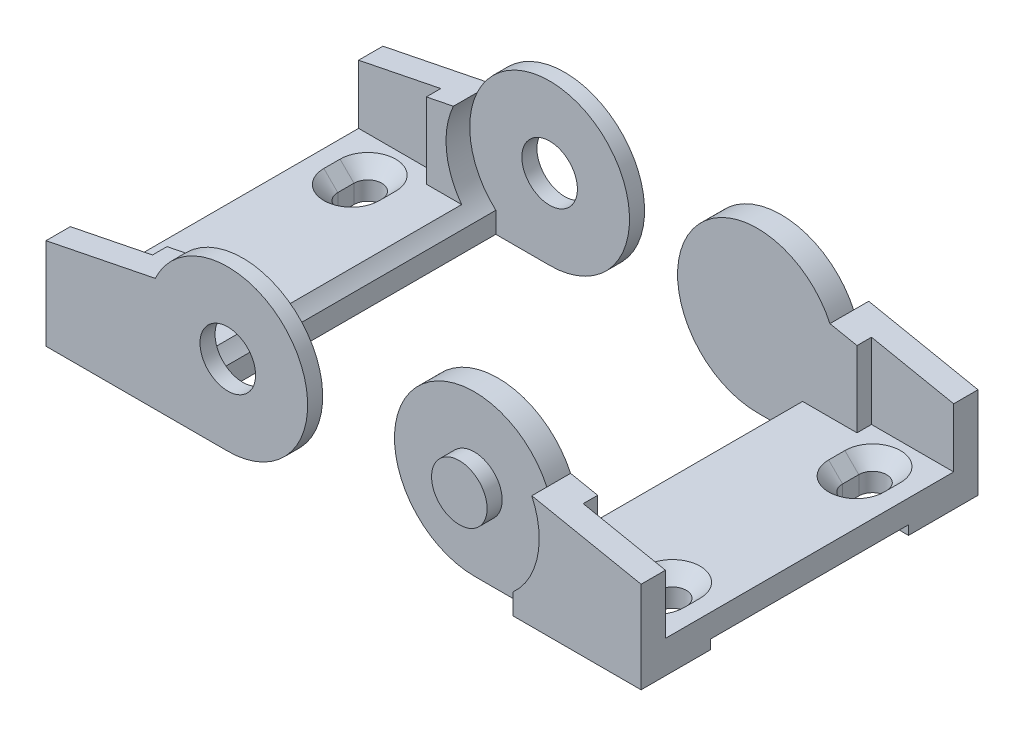
from build123d import *

# Parameters (mm, degrees)
EXTRUDE1_DEPTH          = 36.957
CUT_EXTRUDE1_DEPTH      = 31.623
CUT_EXTRUDE1_DEPTH_BACK = 31.623
CUT_EXTRUDE2_DEPTH      = 28.448
SKETCH5_R               = 6.096
CUT_EXTRUDE3_DEPTH      = 3.302
SKETCH6_W               = 6.096
SKETCH6_H               = 43.434
CUT_EXTRUDE4_DEPTH      = 2.032
CUT_EXTRUDE5_DEPTH      = 4.064
CUT_EXTRUDE6_DEPTH      = 3.048
CUT_EXTRUDE6_TAPER      = -45
EXTRUDE2_DEPTH          = 3.302
EXTRUDE3_DEPTH          = 3.302
CUT_EXTRUDE7_START      = -33.655
CUT_EXTRUDE7_DEPTH      = 67.31
SKETCH9_R               = 6.096
CUT_EXTRUDE8_DEPTH      = 74.914


with BuildPart() as part:
    # Sketch2 → Extrude1 (new body, symmetric)
    with BuildSketch(Plane.XY):
        with BuildLine():
            Line((0, -17.526), (39.878, -17.526))
            Line((39.878, -17.526), (39.878, 2.54))
            Line((39.878, 2.54), (15.902915456, 7.366))
            ThreePointArc((15.902915456, 7.366), (-14.769177228, 9.435681215), (0, -17.526))
        make_face()
    extrude(amount=EXTRUDE1_DEPTH, both=True)

    # Sketch3 → Cut-Extrude1 (cut, two sides)
    with BuildSketch(Plane.XY) as cut_extrude1_sk:
        Polygon((39.878, -10.414), (39.878, 2.54), (21.844, 6.170105405), (21.844, -10.414), align=None)
    extrude(amount=CUT_EXTRUDE1_DEPTH, mode=Mode.SUBTRACT)
    extrude(cut_extrude1_sk.sketch, amount=-CUT_EXTRUDE1_DEPTH_BACK, mode=Mode.SUBTRACT)

    # Sketch4 → Cut-Extrude2 (cut, symmetric)
    with BuildSketch(Plane.XY):
        with BuildLine():
            Line((9.906, -10.414), (39.878, -10.414))
            Line((39.878, -10.414), (39.878, 2.54))
            Line((39.878, 2.54), (15.902915456, 7.366))
            ThreePointArc((15.902915456, 7.366), (-14.769177228, 9.435681215), (0, -17.526))
            Line((0, -17.526), (9.906, -17.526))
            Line((9.906, -17.526), (9.906, -10.414))
        make_face()
    extrude(amount=CUT_EXTRUDE2_DEPTH, both=True, mode=Mode.SUBTRACT)

    # Sketch5 → Cut-Extrude3 (cut)
    with BuildSketch(Plane.XY.offset(36.957)):
        with BuildLine():
            Line((0, -17.526), (11.804853239, -17.526))
            Line((11.804853239, -17.526), (11.804853239, -12.954))
            ThreePointArc((11.804853239, -12.954), (-6.329647384, 16.343079269), (0, -17.526))
        make_face()
        Circle(SKETCH5_R, mode=Mode.SUBTRACT)
    cut_extrude3 = extrude(amount=-CUT_EXTRUDE3_DEPTH, mode=Mode.SUBTRACT)

    # Sketch6 → Cut-Extrude4 (cut)
    with BuildSketch(Plane.XZ.offset(17.526)):
        with Locations((36.83, 0)):
            Rectangle(SKETCH6_W, SKETCH6_H)
    extrude(amount=-CUT_EXTRUDE4_DEPTH, mode=Mode.SUBTRACT)

    # Sketch7 → Cut-Extrude5 (cut)
    with BuildSketch(Plane.XZ.offset(17.526)):
        with BuildLine():
            Line((26.924, 23.749), (26.924, 20.193))
            ThreePointArc((26.924, 20.193), (29.972, 17.145), (33.02, 20.193))
            Line((33.02, 20.193), (33.02, 23.749))
            ThreePointArc((33.02, 23.749), (29.972, 26.797), (26.924, 23.749))
        make_face()
    cut_extrude5 = extrude(amount=-CUT_EXTRUDE5_DEPTH, mode=Mode.SUBTRACT)

    # Sketch8 → Cut-Extrude6 (cut)
    with BuildSketch(Plane.XZ.offset(13.462)):
        with BuildLine():
            Line((26.924, 23.749), (26.924, 20.193))
            ThreePointArc((26.924, 20.193), (29.972, 17.145), (33.02, 20.193))
            Line((33.02, 20.193), (33.02, 23.749))
            ThreePointArc((33.02, 23.749), (29.972, 26.797), (26.924, 23.749))
        make_face()
    cut_extrude6 = extrude(amount=-CUT_EXTRUDE6_DEPTH, taper=CUT_EXTRUDE6_TAPER, mode=Mode.SUBTRACT)

    # Mirror1: Cut-Extrude3, Cut-Extrude5, Cut-Extrude6 across plane
    add(cut_extrude3.mirror(Plane.XY), mode=Mode.SUBTRACT)
    add(cut_extrude5.mirror(Plane.XY), mode=Mode.SUBTRACT)
    add(cut_extrude6.mirror(Plane.XY), mode=Mode.SUBTRACT)


with BuildPart() as body_2:
    # Mirror3: mirrored copy
    add(part.part.mirror(Plane(origin=(-25.4, 0, 0), x_dir=(0, 0, 1), z_dir=(1, 0, 0))))

    # Sketch10 → Extrude2 (add)
    with BuildSketch(Plane.XY.offset(33.655)):
        with BuildLine():
            Line((-62.604853239, -12.954), (-62.604853239, -17.526))
            Line((-62.604853239, -17.526), (-50.8, -17.526))
            ThreePointArc((-50.8, -17.526), (-36.030822772, 9.435681215), (-66.702915456, 7.366))
            ThreePointArc((-66.702915456, 7.366), (-67.980096377, -3.464818102), (-62.604853239, -12.954))
        make_face()
    extrude(amount=EXTRUDE2_DEPTH)

    # Sketch11 → Extrude3 (add)
    with BuildSketch(Plane(origin=(0, 0, -33.655), x_dir=(-1, 0, 0), z_dir=(0, 0, -1))):
        with BuildLine():
            Line((50.8, -17.526), (62.604853239, -17.526))
            Line((62.604853239, -17.526), (62.604853239, -12.954))
            ThreePointArc((62.604853239, -12.954), (67.980096377, -3.464818102), (66.702915456, 7.366))
            ThreePointArc((66.702915456, 7.366), (36.030822772, 9.435681215), (50.8, -17.526))
        make_face()
    extrude(amount=EXTRUDE3_DEPTH)

    # Sketch12 → Cut-Extrude7 (cut)
    with BuildSketch(Plane.XY.offset(CUT_EXTRUDE7_START)):
        with BuildLine():
            Line((-62.604853239, -12.954), (-62.604853239, -17.526))
            Line((-62.604853239, -17.526), (-50.8, -17.526))
            ThreePointArc((-50.8, -17.526), (-36.030822772, 9.435681215), (-66.702915456, 7.366))
            ThreePointArc((-66.702915456, 7.366), (-67.980096377, -3.464818102), (-62.604853239, -12.954))
        make_face()
    extrude(amount=CUT_EXTRUDE7_DEPTH, mode=Mode.SUBTRACT)

    # Sketch9 → Cut-Extrude8 (cut, through all)
    with BuildSketch(Plane.XY.offset(36.957)):
        with Locations((-50.8, 0)):
            Circle(SKETCH9_R)
    extrude(amount=-CUT_EXTRUDE8_DEPTH, mode=Mode.SUBTRACT)


solid = Compound([part.part, body_2.part])
